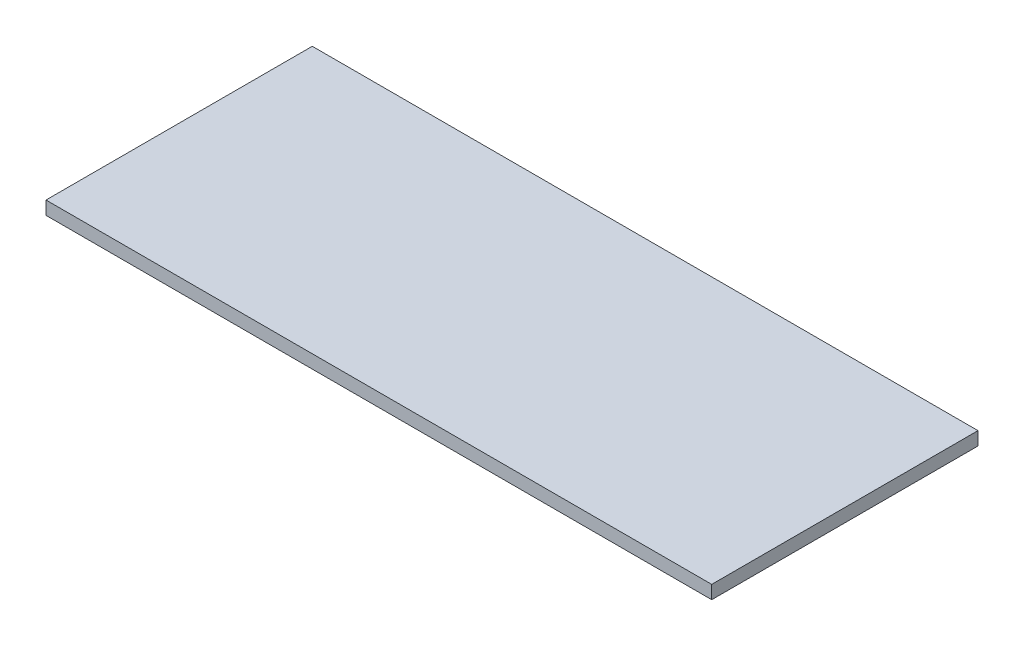
from build123d import *

# Parameters (mm, degrees)
SKETCH1_W           = 200
SKETCH1_H           = 80
BOSS_EXTRUDE1_DEPTH = 4


with BuildPart() as part:
    # Sketch1 → Boss-Extrude1 (new body)
    with BuildSketch(Plane(origin=(0, 0, 0), x_dir=(1, 0, 0), z_dir=(0, 1, 0))):
        Rectangle(SKETCH1_W, SKETCH1_H)
    extrude(amount=BOSS_EXTRUDE1_DEPTH)


solid = part.part
